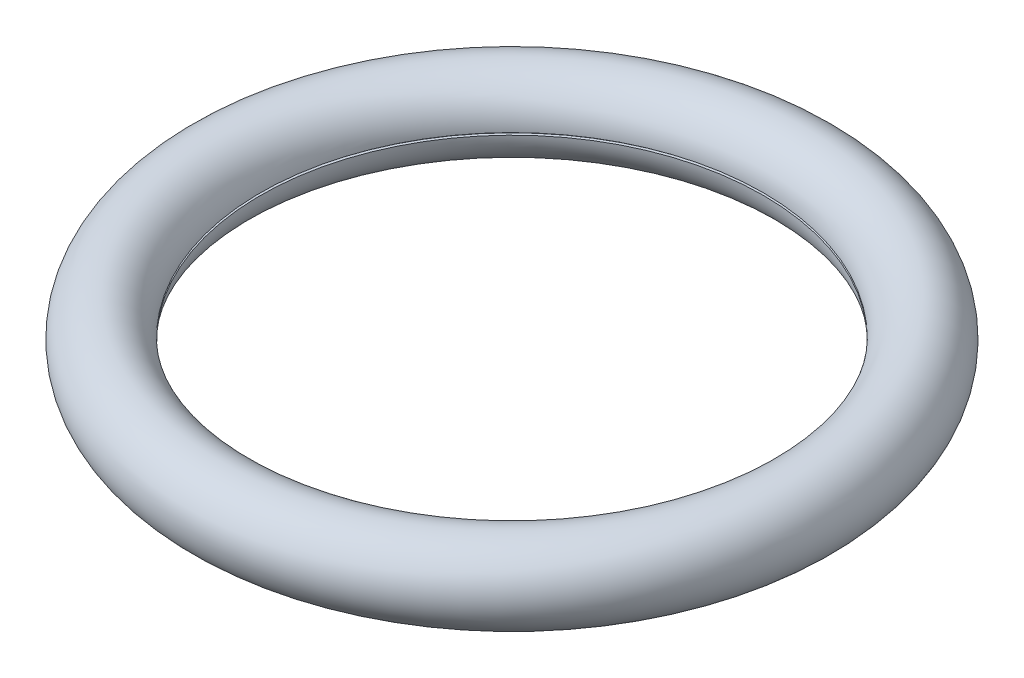
from build123d import *

# Parameters (mm, degrees)
SKETCH1_R          = 13.7
SKETCH1_R_2        = 12.7
SKETCH3_R          = 107.95
CUT_EXTRUDE1_DEPTH = 0.078125
SKETCH4_R          = 107.95
CUT_EXTRUDE2_DEPTH = 0.396875


with BuildPart() as part:
    # Sketch1 → Revolve1 (revolve)
    with BuildSketch(Plane.XY):
        with Locations((101.6, 0)):
            Circle(SKETCH1_R)
        with Locations((101.6, 0)):
            Circle(SKETCH1_R_2, mode=Mode.SUBTRACT)
    revolve(axis=Axis((0, 3.175, 0), (0, -1, 0)))

    # Sketch3 → Cut-Extrude1 (cut, symmetric)
    with BuildSketch(Plane(origin=(0, 0, 0), x_dir=(1, 0, 0), z_dir=(0, 1, 0))):
        Circle(SKETCH3_R)
        with BuildLine():
            ThreePointArc((27.757566502, -91.11575057), (67.351920908, -67.351920908), (91.11575057, -27.757566502))
            ThreePointArc((91.11575057, -27.757566502), (89.903527616, -21.822714376), (84.266922058, -19.60446461))
            ThreePointArc((84.266922058, -19.60446461), (40.804807613, -40.804807613), (19.60446461, -84.266922058))
            ThreePointArc((19.60446461, -84.266922058), (21.822714376, -89.903527616), (27.757566502, -91.11575057))
        make_face(mode=Mode.SUBTRACT)
        with BuildLine():
            ThreePointArc((-81.63869201, 23.668181818), (0, 38.1), (81.63869201, 23.668181818))
            ThreePointArc((81.63869201, 23.668181818), (88.283116885, 25.120584837), (89.802561211, 31.75))
            ThreePointArc((89.802561211, 31.75), (0, 95.25), (-89.802561211, 31.75))
            ThreePointArc((-89.802561211, 31.75), (-88.283116885, 25.120584837), (-81.63869201, 23.668181818))
        make_face(mode=Mode.SUBTRACT)
        with BuildLine():
            ThreePointArc((-84.266922058, -19.60446461), (-40.804807613, -40.804807613), (-19.60446461, -84.266922058))
            ThreePointArc((-19.60446461, -84.266922058), (-21.822714376, -89.903527616), (-27.757566502, -91.11575057))
            ThreePointArc((-27.757566502, -91.11575057), (-67.351920908, -67.351920908), (-91.11575057, -27.757566502))
            ThreePointArc((-91.11575057, -27.757566502), (-89.903527616, -21.822714376), (-84.266922058, -19.60446461))
        make_face(mode=Mode.SUBTRACT)
    extrude(amount=CUT_EXTRUDE1_DEPTH, both=True, mode=Mode.SUBTRACT)

    # Sketch4 → Cut-Extrude2 (cut, symmetric)
    with BuildSketch(Plane(origin=(0, 0, 0), x_dir=(1, 0, 0), z_dir=(0, 1, 0))):
        Circle(SKETCH4_R)
    extrude(amount=CUT_EXTRUDE2_DEPTH, both=True, mode=Mode.SUBTRACT)


solid = part.part
